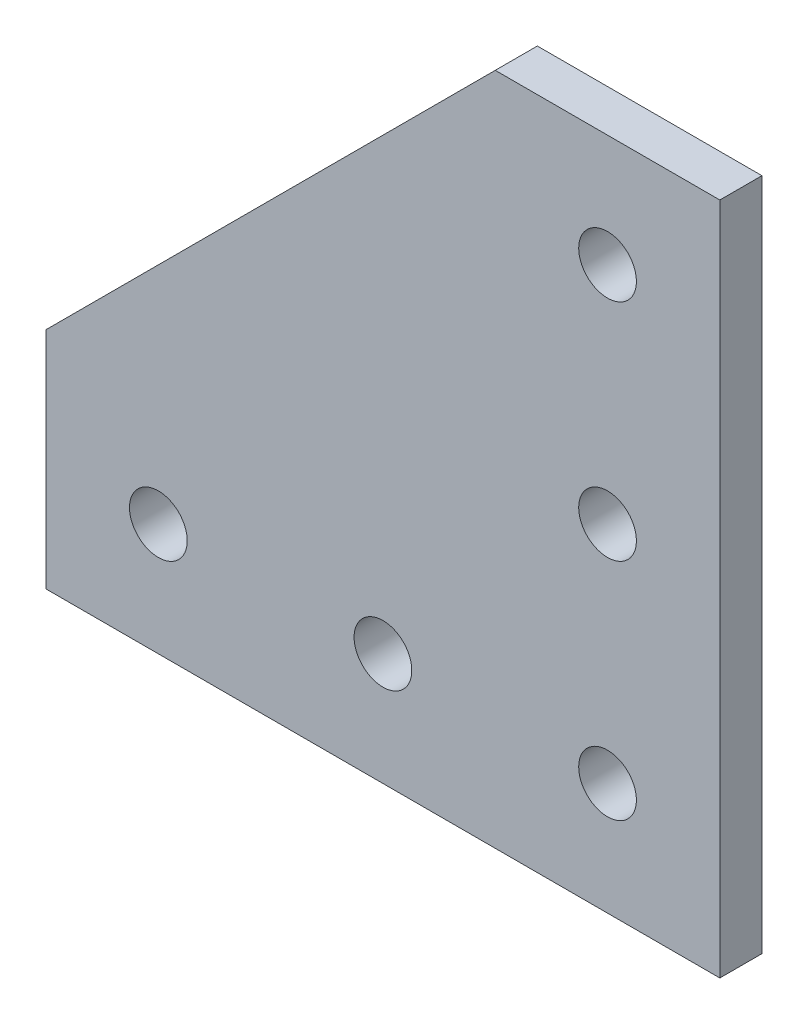
from build123d import *

# Parameters (mm, degrees)
EXTRUDE1_DEPTH  = 4.7625
SKETCH2_R       = 3.2639
SINGLE_90_DEPTH = 5.7625


with BuildPart() as part:
    # Sketch1 → Extrude1 (new body)
    with BuildSketch(Plane.XY):
        Polygon((25.4, 25.4), (50.8, 25.4), (50.8, -50.8), (-25.4, -50.8), (-25.4, -25.4), align=None)
    extrude(amount=-EXTRUDE1_DEPTH)

    # Sketch2 → single 90 (cut, through all)
    with BuildSketch(Plane(origin=(0, 0, -4.7625), x_dir=(-1, 0, 0), z_dir=(0, 0, -1))):
        with Locations((-38.1, -38.1)):
            Circle(SKETCH2_R)
        with Locations((-12.7, -38.1)):
            Circle(SKETCH2_R)
        with Locations((12.7, -38.1)):
            Circle(SKETCH2_R)
        with Locations((-38.1, -12.7)):
            Circle(SKETCH2_R)
        with Locations((-38.1, 12.7)):
            Circle(SKETCH2_R)
    extrude(amount=-SINGLE_90_DEPTH, mode=Mode.SUBTRACT)


solid = part.part
